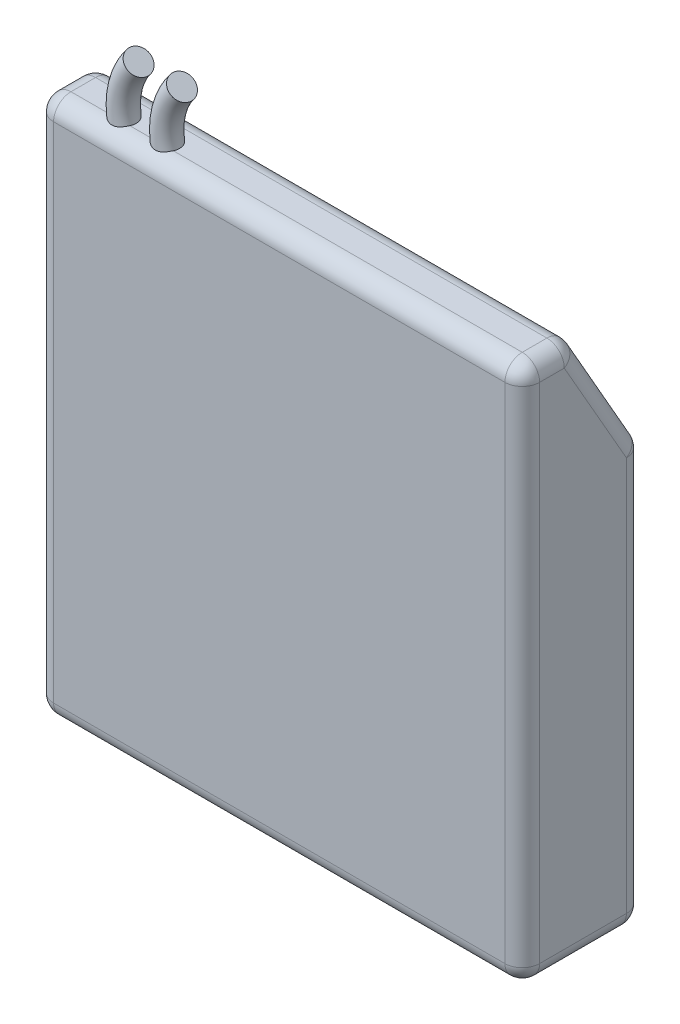
from build123d import *

# Parameters (mm, degrees)
EXTRUDE_1_DEPTH        = 28
FILLET_1_R             = 1
SWEEP_1_PROFILE_R      = 0.7
PATTERN_LINEAR_1_COUNT = 2
PATTERN_LINEAR_1_PITCH = 2.5


with BuildPart() as part:
    # 草图1 → 凸台-拉伸1 (new body)
    with BuildSketch(Plane(origin=(0, 0, 0), x_dir=(0, 0, -1), z_dir=(1, 0, 0))):
        Polygon((0, 0), (0, 31), (3, 31), (7, 24), (7, 0), align=None)
    extrude(amount=EXTRUDE_1_DEPTH)

    # 圆角1
    fillet_1_edges = [part.edges().sort_by_distance(p)[0] for p in [
        (28, 27.5, -5),
        (28, 31, -1.5),
        (28, 15.5, 0),
        (28, 0, -3.5),
        (0, 15.5, 0),
        (0, 31, -1.5),
        (0, 27.5, -5),
        (0, 12, -7),
        (0, 0, -3.5),
        (28, 12, -7),
        (14, 0, 0),
        (14, 31, 0),
        (14, 31, -3),
        (14, 24, -7),
        (14, 0, -7),
    ]]
    fillet(fillet_1_edges, radius=FILLET_1_R)

    # 扫描1: sweep along a path in 草图2
    with BuildLine(Plane.XY.offset(-1.3)) as sweep_1_path:
        ThreePointArc((4.647498894, 28.922984251), (3.714501518, 31.52399057), (4.597001461, 34.142561139))
    # 扫描1 profile (on start of the path) → 扫描1 (sweep)
    with BuildSketch(Plane(origin=(4.647498894, 28.922984251, -1.3), x_dir=(0.778109821, 0.628128256, 0), z_dir=(-0.628128256, 0.778109821, 0))):
        Circle(SWEEP_1_PROFILE_R)
    sweep_1 = sweep(path=sweep_1_path.line)

    # 阵列(线性)1: 扫描1 ×2
    with Locations(*[(i * PATTERN_LINEAR_1_PITCH, 0, 0) for i in range(1, PATTERN_LINEAR_1_COUNT)]):
        add(sweep_1)


solid = part.part
